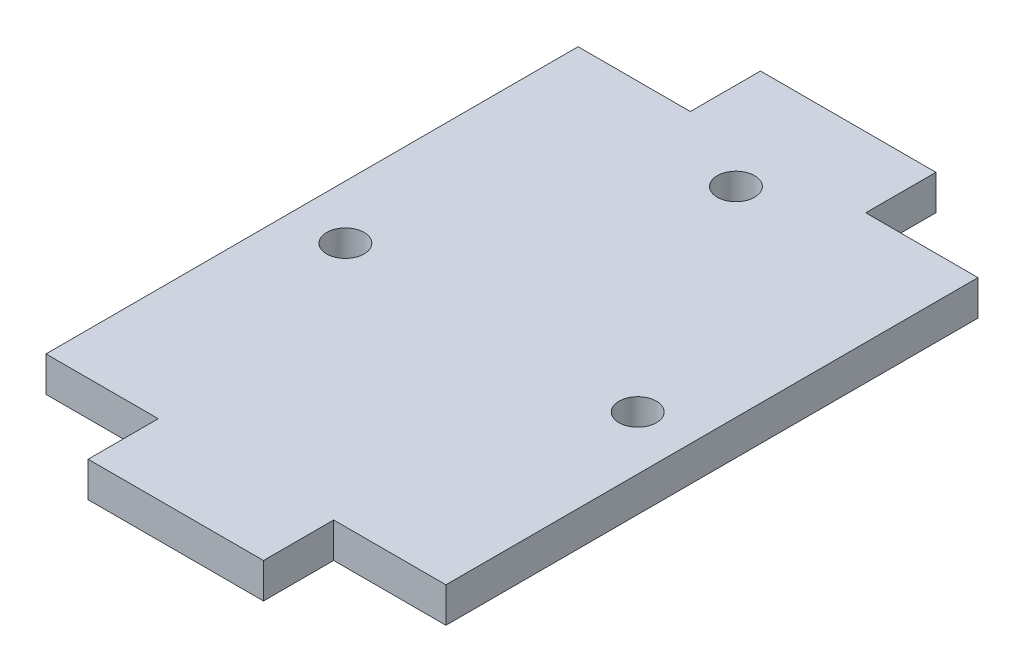
from build123d import *

# Parameters (mm, degrees)
ESBO_O1_R                = 1.6
RESSALTO_EXTRUS_O1_DEPTH = 3


with BuildPart() as part:
    # Esboço1 → Ressalto-extrusão1 (new body)
    with BuildSketch(Plane.XZ.offset(6)):
        Polygon((17.1, 41.9), (7.5, 41.9), (7.5, 47.9), (-7.5, 47.9), (-7.5, 41.9), (-17.1, 41.9), (-17.1, -3.6), (-7.5, -3.6), (-7.5, -9.6), (7.5, -9.6), (7.5, -3.6), (17.1, -3.6), align=None)
        with Locations((-12.5, 20.9)):
            Circle(ESBO_O1_R, mode=Mode.SUBTRACT)
        Circle(ESBO_O1_R, mode=Mode.SUBTRACT)
        with Locations((12.5, 20.9)):
            Circle(ESBO_O1_R, mode=Mode.SUBTRACT)
    extrude(amount=-RESSALTO_EXTRUS_O1_DEPTH)


solid = part.part
